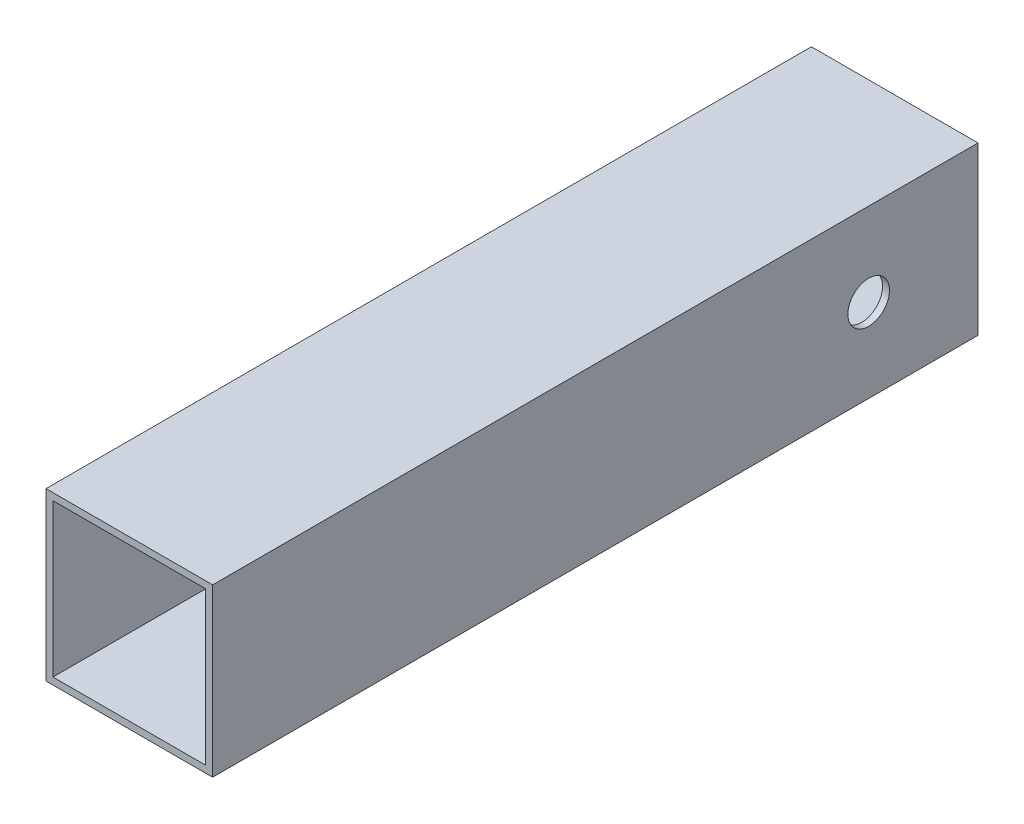
from build123d import *

# Parameters (mm, degrees)
CROQUIS1_W              = 76.2
CROQUIS1_H              = 76.2
CROQUIS1_W_2            = 69.85
CROQUIS1_H_2            = 69.85
SALIENTE_EXTRUIR1_DEPTH = 350
CROQUIS3_R              = 9.525
CORTAR_EXTRUIR2_DEPTH   = 127


with BuildPart() as part:
    # Croquis1 → Saliente-Extruir1 (new body)
    with BuildSketch(Plane.XY):
        with Locations((38.1, -38.1)):
            Rectangle(CROQUIS1_W, CROQUIS1_H)
        with Locations((38.1, -38.1)):
            Rectangle(CROQUIS1_W_2, CROQUIS1_H_2, mode=Mode.SUBTRACT)
    extrude(amount=SALIENTE_EXTRUIR1_DEPTH)

    # Croquis3 → Cortar-Extruir2 (cut)
    with BuildSketch(Plane.ZY):
        with Locations((50, -38.1)):
            Circle(CROQUIS3_R)
    extrude(amount=-CORTAR_EXTRUIR2_DEPTH, mode=Mode.SUBTRACT)


solid = part.part
